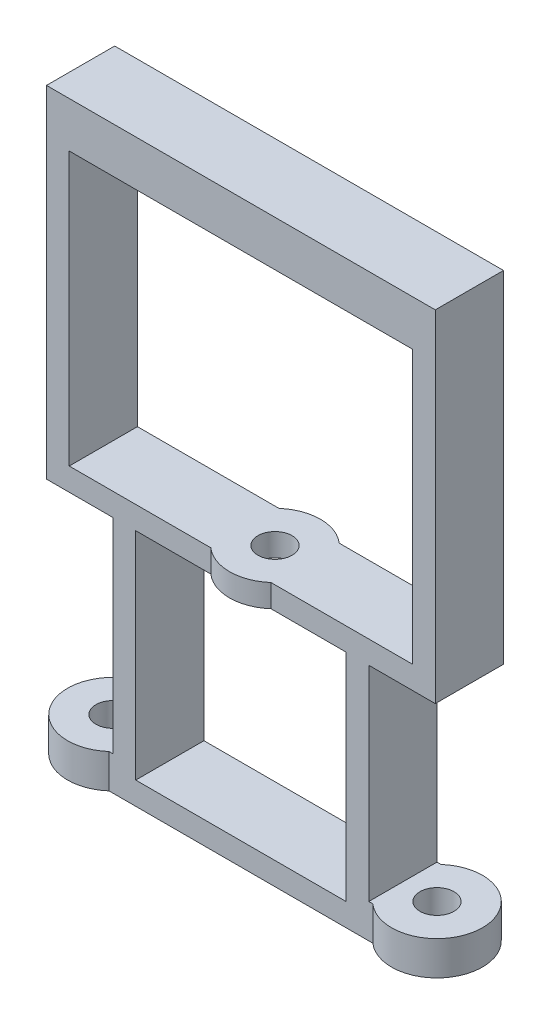
from build123d import *

# Parameters (mm, degrees)
SKETCH1_R           = 1.5
BOSS_EXTRUDE1_DEPTH = 3
SKETCH2_W           = 22.5
SKETCH2_H           = 6
BOSS_EXTRUDE2_DEPTH = 20
SKETCH3_W           = 18.5
SKETCH3_H           = 19
CUT_EXTRUDE1_DEPTH  = 10
SKETCH4_W           = 3.85
SKETCH4_H           = 6
BOSS_EXTRUDE3_DEPTH = 2
SKETCH5_R           = 1.5
CUT_EXTRUDE2_DEPTH  = 2
SKETCH6_W           = 6
SKETCH6_H           = 2
BOSS_EXTRUDE4_DEPTH = 2
SKETCH7_W           = 2
SKETCH7_H           = 6
BOSS_EXTRUDE5_DEPTH = 28
SKETCH8_W           = 6
SKETCH8_H           = 2
BOSS_EXTRUDE6_DEPTH = 2
SKETCH9_W           = 2
SKETCH9_H           = 6
BOSS_EXTRUDE7_DEPTH = 28
SKETCH11_W          = 6
SKETCH11_H          = 4
BOSS_EXTRUDE8_DEPTH = 31


with BuildPart() as part:
    # Sketch1 → Boss-Extrude1 (new body)
    with BuildSketch(Plane(origin=(0, 0, 0), x_dir=(1, 0, 0), z_dir=(0, 1, 0))):
        with BuildLine():
            Line((2.645751311, 3), (25.854248689, 3))
            ThreePointArc((25.854248689, 3), (32.5, 0), (25.854248689, -3))
            Line((25.854248689, -3), (2.645751311, -3))
            ThreePointArc((2.645751311, -3), (-4, 0), (2.645751311, 3))
        make_face()
        Circle(SKETCH1_R, mode=Mode.SUBTRACT)
        with Locations((28.5, 0)):
            Circle(SKETCH1_R, mode=Mode.SUBTRACT)
    extrude(amount=BOSS_EXTRUDE1_DEPTH)

    # Sketch2 → Boss-Extrude2 (add)
    with BuildSketch(Plane(origin=(0, 3, 0), x_dir=(1, 0, 0), z_dir=(0, 1, 0))):
        with Locations((14.25, 0)):
            Rectangle(SKETCH2_W, SKETCH2_H)
    extrude(amount=BOSS_EXTRUDE2_DEPTH)

    # Sketch3 → Cut-Extrude1 (cut)
    with BuildSketch(Plane.XY.offset(3)):
        with Locations((14.25, 11.5)):
            Rectangle(SKETCH3_W, SKETCH3_H)
    extrude(amount=-CUT_EXTRUDE1_DEPTH, mode=Mode.SUBTRACT)

    # Sketch4 → Boss-Extrude3 (add)
    with BuildSketch(Plane(origin=(0, 23, 0), x_dir=(1, 0, 0), z_dir=(0, 1, 0))):
        with BuildLine():
            Line((11.604248689, 3), (16.895751311, 3))
            ThreePointArc((16.895751311, 3), (14.25, 4), (11.604248689, 3))
        make_face()
        with Locations((27.425, 0)):
            Rectangle(SKETCH4_W, SKETCH4_H)
        with Locations((1.075, 0)):
            Rectangle(SKETCH4_W, SKETCH4_H)
        with BuildLine():
            ThreePointArc((11.604248689, -3), (14.25, -4), (16.895751311, -3))
            Line((16.895751311, -3), (11.604248689, -3))
        make_face()
    extrude(amount=-BOSS_EXTRUDE3_DEPTH)

    # Sketch5 → Cut-Extrude2 (cut)
    with BuildSketch(Plane(origin=(0, 23, 0), x_dir=(1, 0, 0), z_dir=(0, 1, 0))):
        with Locations((14.25, 0)):
            Circle(SKETCH5_R)
    extrude(amount=-CUT_EXTRUDE2_DEPTH, mode=Mode.SUBTRACT)

    # Sketch6 → Boss-Extrude4 (add)
    with BuildSketch(Plane.ZY.offset(0.85)):
        with Locations((0, 22)):
            Rectangle(SKETCH6_W, SKETCH6_H)
    extrude(amount=BOSS_EXTRUDE4_DEPTH)

    # Sketch7 → Boss-Extrude5 (add)
    with BuildSketch(Plane(origin=(0, 23, 0), x_dir=(1, 0, 0), z_dir=(0, 1, 0))):
        with Locations((-1.85, 0)):
            Rectangle(SKETCH7_W, SKETCH7_H)
    extrude(amount=BOSS_EXTRUDE5_DEPTH)

    # Sketch8 → Boss-Extrude6 (add)
    with BuildSketch(Plane(origin=(29.35, 0, 0), x_dir=(0, 0, -1), z_dir=(1, 0, 0))):
        with Locations((0, 22)):
            Rectangle(SKETCH8_W, SKETCH8_H)
    extrude(amount=BOSS_EXTRUDE6_DEPTH)

    # Sketch9 → Boss-Extrude7 (add)
    with BuildSketch(Plane(origin=(0, 23, 0), x_dir=(1, 0, 0), z_dir=(0, 1, 0))):
        with Locations((30.35, 0)):
            Rectangle(SKETCH9_W, SKETCH9_H)
    extrude(amount=BOSS_EXTRUDE7_DEPTH)

    # Sketch11 → Boss-Extrude8 (add)
    with BuildSketch(Plane.ZY.offset(-29.35)):
        with Locations((0, 49)):
            Rectangle(SKETCH11_W, SKETCH11_H)
    extrude(amount=BOSS_EXTRUDE8_DEPTH)


solid = part.part
